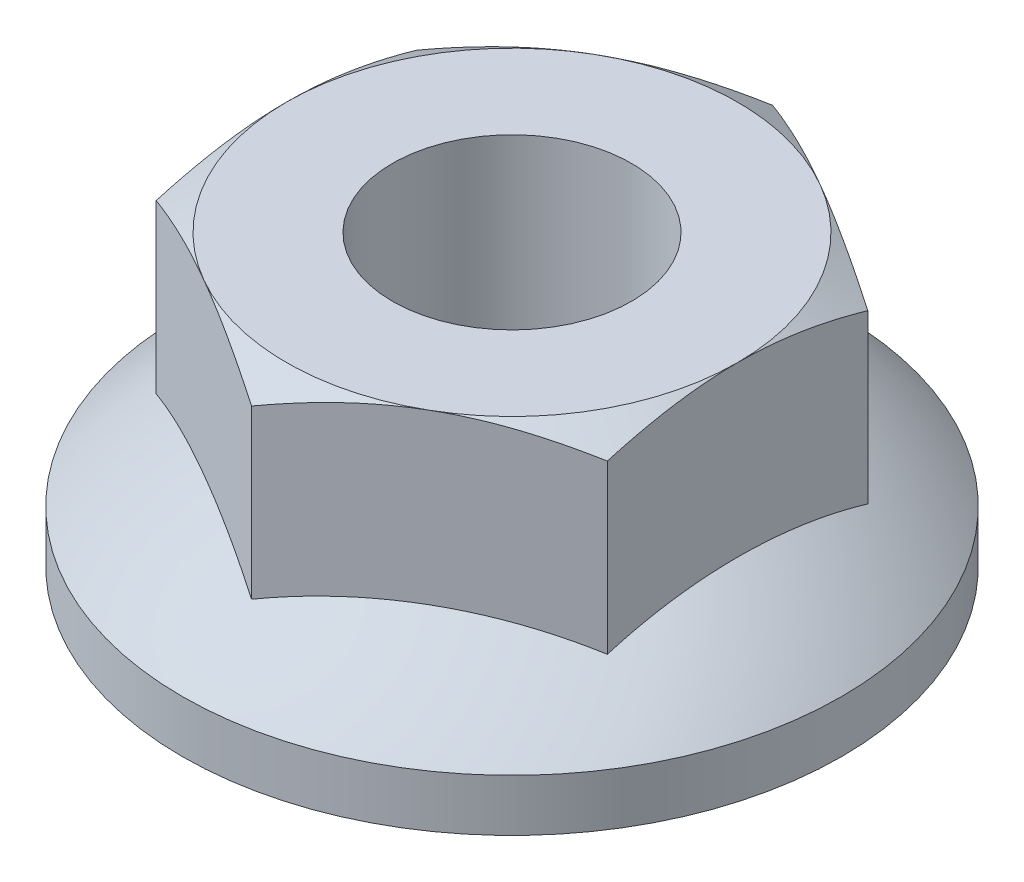
from build123d import *

# Parameters (mm, degrees)
BOSS_EXTRUDE1_DEPTH = 5
TAP1_D              = 4.134


with BuildPart() as part:
    # Sketch1 → Revolve1 (revolve)
    with BuildSketch(Plane.XY):
        with BuildLine():
            Line((0, 0), (-5.7, 0))
            Line((-5.7, 0), (-5.7, 0.9))
            ThreePointArc((-5.7, 0.9), (-3.03726851, 2.458300241), (0, 3))
            Line((0, 3), (0, 0))
        make_face()
    revolve(axis=Axis((0, 55, 0), (0, -1, 0)))

    # Sketch2 → Boss-Extrude1 (add)
    with BuildSketch(Plane.XZ):
        Polygon((0, 4.5033321), (-3.9, 2.25166605), (-3.9, -2.25166605), (0, -4.5033321), (3.9, -2.25166605), (3.9, 2.25166605), align=None)
    extrude(amount=-BOSS_EXTRUDE1_DEPTH)

    # Sketch3 → Cut-Revolve1 (revolve, cut)
    with BuildSketch(Plane.XY):
        Polygon((-3.9, 5), (-5.9, 5), (-5.9, 3.845299462), align=None)
    revolve(axis=Axis((0, 55, 0), (0, -1, 0)), mode=Mode.SUBTRACT)

    # Tap1 (through all)
    with Locations(Plane(origin=(0, 5, 0), x_dir=(1, 0, 0), z_dir=(0, 1, 0))):
        with Locations((0, 0)):
            Hole(TAP1_D / 2)


solid = part.part
